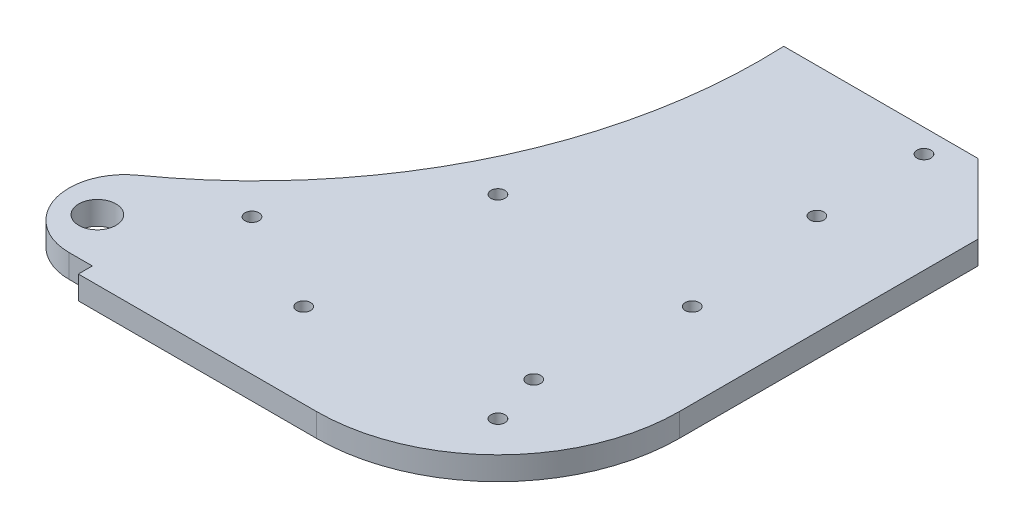
from build123d import *

# Parameters (mm, degrees)
BOSS_EXTRU_1_DEPTH      = 5
ESQUISSE2_R             = 1.5
ENL_V_MAT_EXTRU_1_DEPTH = 6
ESQUISSE3_R             = 1.5
ENL_V_MAT_EXTRU_2_DEPTH = 6
ESQUISSE4_R             = 4
ENL_V_MAT_EXTRU_3_DEPTH = 6


with BuildPart() as part:
    # Esquisse1 → Boss.-Extru.1 (new body)
    with BuildSketch(Plane(origin=(0, 0, 0), x_dir=(1, 0, 0), z_dir=(0, 1, 0))):
        with BuildLine():
            Line((-51.1, -39), (0, -39))
            ThreePointArc((0, -39), (27.577164466, -27.577164466), (39, 0))
            Line((39, 0), (39, 64.082873123))
            Line((39, 64.082873123), (24, 79.082873123))
            Line((24, 79.082873123), (-17.715268603, 79.082873123))
            ThreePointArc((-17.715268603, 79.082873123), (-28.51615758, 26.652464115), (-63.070954357, -14.232410975))
            ThreePointArc((-63.070954357, -14.232410975), (-67.528277829, -27.659845058), (-56.1, -36))
            Line((-56.1, -36), (-51.1, -36))
            Line((-51.1, -36), (-51.1, -39))
        make_face()
    extrude(amount=BOSS_EXTRU_1_DEPTH)

    # Esquisse2 → Enlèv. mat.-Extru.1 (cut, through all)
    with BuildSketch(Plane.XZ):
        with Locations((20.859650045, 20.859650045)):
            Circle(ESQUISSE2_R)
        with Locations((20.859650045, -20.859650045)):
            Circle(ESQUISSE2_R)
        with Locations((-20.859650045, -20.859650045)):
            Circle(ESQUISSE2_R)
        with Locations((-20.859650045, 20.859650045)):
            Circle(ESQUISSE2_R)
        with Locations((17.4, -74.082873123)):
            Circle(ESQUISSE2_R)
        with Locations((17.4, 9.717126877)):
            Circle(ESQUISSE2_R)
    extrude(amount=-ENL_V_MAT_EXTRU_1_DEPTH, mode=Mode.SUBTRACT)

    # Esquisse3 → Enlèv. mat.-Extru.2 (cut, through all)
    with BuildSketch(Plane(origin=(0, 5, 0), x_dir=(1, 0, 0), z_dir=(0, 1, 0))):
        with Locations((17.4, 51.082873123)):
            Circle(ESQUISSE3_R)
        with Locations((-43.1, -9.717126877)):
            Circle(ESQUISSE3_R)
    extrude(amount=-ENL_V_MAT_EXTRU_2_DEPTH, mode=Mode.SUBTRACT)

    # Esquisse4 → Enlèv. mat.-Extru.3 (cut, through all)
    with BuildSketch(Plane(origin=(0, 5, 0), x_dir=(1, 0, 0), z_dir=(0, 1, 0))):
        with Locations((-60.1, -25.917126877)):
            Circle(ESQUISSE4_R)
    extrude(amount=-ENL_V_MAT_EXTRU_3_DEPTH, mode=Mode.SUBTRACT)


solid = part.part
